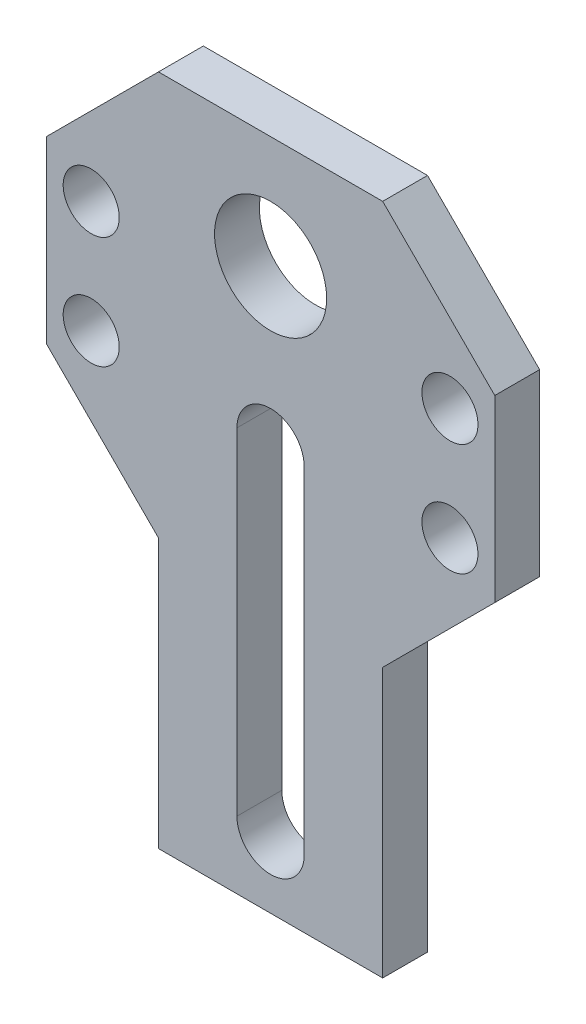
from build123d import *

# Parameters (mm, degrees)
SKETCH1_W           = 10
SKETCH1_H           = 30
BOSS_EXTRUDE1_DEPTH = 2
SKETCH2_R           = 2.5
CUT_EXTRUDE1_DEPTH  = 2
CUT_EXTRUDE2_DEPTH  = 2
BOSS_EXTRUDE2_DEPTH = 2
SKETCH5_R           = 1.25
CUT_EXTRUDE3_DEPTH  = 2


with BuildPart() as part:
    # Sketch1 → Boss-Extrude1 (new body)
    with BuildSketch(Plane.XY):
        with Locations((5, 15)):
            Rectangle(SKETCH1_W, SKETCH1_H)
    extrude(amount=BOSS_EXTRUDE1_DEPTH)

    # Sketch2 → Cut-Extrude1 (cut)
    with BuildSketch(Plane.XY.offset(2)):
        with Locations((5, 25)):
            Circle(SKETCH2_R)
    extrude(amount=-CUT_EXTRUDE1_DEPTH, mode=Mode.SUBTRACT)

    # Sketch3 → Cut-Extrude2 (cut)
    with BuildSketch(Plane.XY.offset(2)):
        with BuildLine():
            Line((3.5, 3), (3.5, 18))
            ThreePointArc((3.5, 18), (5, 19.5), (6.5, 18))
            Line((6.5, 18), (6.5, 3))
            ThreePointArc((6.5, 3), (5, 1.5), (3.5, 3))
        make_face()
    extrude(amount=-CUT_EXTRUDE2_DEPTH, mode=Mode.SUBTRACT)

    # Sketch4 → Boss-Extrude2 (add)
    with BuildSketch(Plane.XY.offset(2)):
        Polygon((0, 30), (-5, 25), (-5, 17), (0, 12), align=None)
        Polygon((10, 30), (15, 25), (15, 17), (10, 12), align=None)
    extrude(amount=-BOSS_EXTRUDE2_DEPTH)

    # Sketch5 → Cut-Extrude3 (cut)
    with BuildSketch(Plane.XY.offset(2)):
        with Locations((-3, 23.5)):
            Circle(SKETCH5_R)
        with Locations((-3, 18.5)):
            Circle(SKETCH5_R)
        with Locations((13, 18.5)):
            Circle(SKETCH5_R)
        with Locations((13, 23.5)):
            Circle(SKETCH5_R)
    extrude(amount=-CUT_EXTRUDE3_DEPTH, mode=Mode.SUBTRACT)


solid = part.part
